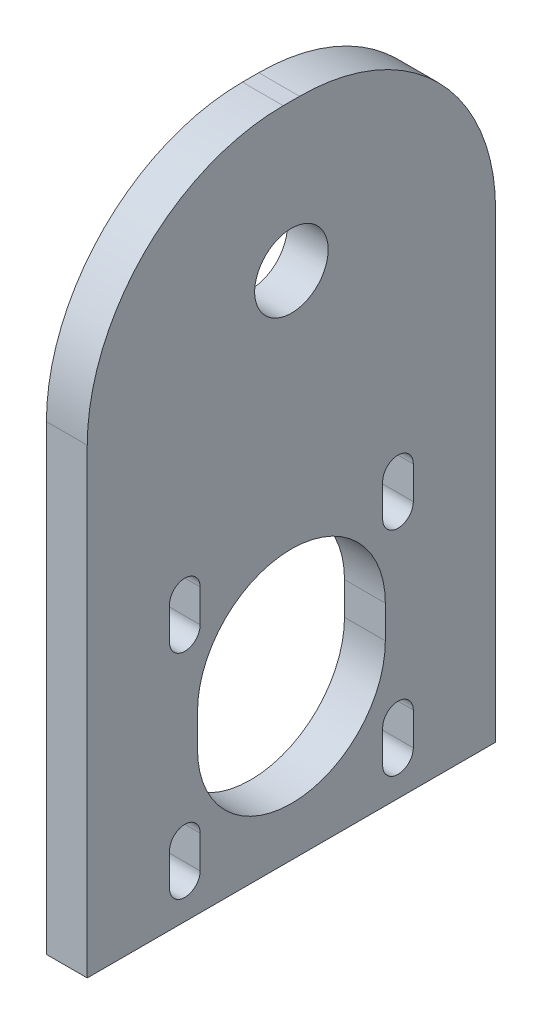
from build123d import *

# Parameters (mm, degrees)
SKETCH1_R           = 4.5
BOSS_EXTRUDE1_DEPTH = 5
SKETCH2_R           = 1.4
CUT_EXTRUDE1_DEPTH  = 10


with BuildPart() as part:
    # Sketch1 → Boss-Extrude1 (new body)
    with BuildSketch(Plane(origin=(0, 0, 0), x_dir=(0, 0, -1), z_dir=(1, 0, 0))):
        with BuildLine():
            Line((9.37337158, 19.191374663), (11.37337158, 19.191374663))
            ThreePointArc((11.37337158, 19.191374663), (28.343934329, 12.161937412), (35.37337158, -4.808625337))
            Line((35.37337158, -4.808625337), (35.37337158, -61.308625337))
            Line((35.37337158, -61.308625337), (-14.62662842, -61.308625337))
            Line((-14.62662842, -61.308625337), (-14.62662842, -4.808625337))
            ThreePointArc((-14.62662842, -4.808625337), (-7.597191168, 12.161937412), (9.37337158, 19.191374663))
        make_face()
        with Locations((10.37337158, 1.191374663)):
            Circle(SKETCH1_R, mode=Mode.SUBTRACT)
        with BuildLine():
            Line((-4.55162842, -26.758625337), (-4.55162842, -30.758625337))
            ThreePointArc((-4.55162842, -30.758625337), (-2.67662842, -32.633625337), (-0.80162842, -30.758625337))
            Line((-0.80162842, -30.758625337), (-0.80162842, -26.758625337))
            ThreePointArc((-0.80162842, -26.758625337), (-2.67662842, -24.883625337), (-4.55162842, -26.758625337))
        make_face(mode=Mode.SUBTRACT)
        with BuildLine():
            Line((21.54837158, -26.758625337), (21.54837158, -30.758625337))
            ThreePointArc((21.54837158, -30.758625337), (23.42337158, -32.633625337), (25.29837158, -30.758625337))
            Line((25.29837158, -30.758625337), (25.29837158, -26.758625337))
            ThreePointArc((25.29837158, -26.758625337), (23.42337158, -24.883625337), (21.54837158, -26.758625337))
        make_face(mode=Mode.SUBTRACT)
        with BuildLine():
            Line((25.29837158, -52.858625337), (25.29837158, -56.858625337))
            ThreePointArc((25.29837158, -56.858625337), (23.42337158, -58.733625337), (21.54837158, -56.858625337))
            Line((21.54837158, -56.858625337), (21.54837158, -52.858625337))
            ThreePointArc((21.54837158, -52.858625337), (23.42337158, -50.983625337), (25.29837158, -52.858625337))
        make_face(mode=Mode.SUBTRACT)
        with BuildLine():
            Line((-4.55162842, -52.858625337), (-4.55162842, -56.858625337))
            ThreePointArc((-4.55162842, -56.858625337), (-2.67662842, -58.733625337), (-0.80162842, -56.858625337))
            Line((-0.80162842, -56.858625337), (-0.80162842, -52.858625337))
            ThreePointArc((-0.80162842, -52.858625337), (-2.67662842, -50.983625337), (-4.55162842, -52.858625337))
        make_face(mode=Mode.SUBTRACT)
        with BuildLine():
            Line((-1.12662842, -39.808625337), (-1.12662842, -43.808625337))
            ThreePointArc((-1.12662842, -43.808625337), (10.37337158, -55.308625337), (21.87337158, -43.808625337))
            Line((21.87337158, -43.808625337), (21.87337158, -39.808625337))
            ThreePointArc((21.87337158, -39.808625337), (10.37337158, -28.308625337), (-1.12662842, -39.808625337))
        make_face(mode=Mode.SUBTRACT)
    extrude(amount=BOSS_EXTRUDE1_DEPTH)

    # Sketch2 → Cut-Extrude1 (cut)
    with BuildSketch(Plane(origin=(0, -61.308625337, 0), x_dir=(-1, 0, 0), z_dir=(0, -1, 0))):
        with Locations((-2.5, -10.62662842)):
            Circle(SKETCH2_R)
        with Locations((-2.5, 31.37337158)):
            Circle(SKETCH2_R)
    extrude(amount=-CUT_EXTRUDE1_DEPTH, mode=Mode.SUBTRACT)


solid = part.part
